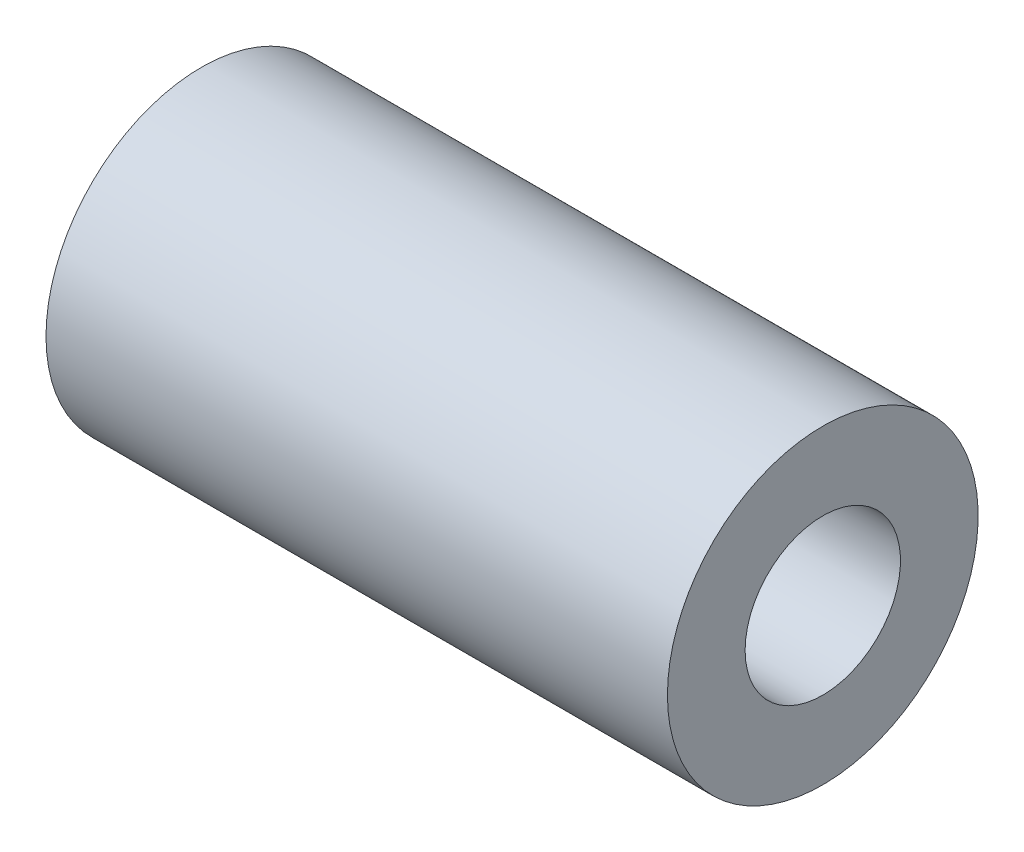
from build123d import *

# Parameters (mm, degrees)
SKETCH1_W         = 10
SKETCH1_H         = 2.5
TROU_TARAUD_M31_D = 2.5


with BuildPart() as part:
    # Sketch1 → Revolve1 (revolve)
    with BuildSketch(Plane.XY):
        with Locations((0, 1.25)):
            Rectangle(SKETCH1_W, SKETCH1_H)
    revolve(axis=Axis((-5, 0, 0), (1, 0, 0)))

    # Trou taraudé M31 (through all)
    with Locations(Plane.ZY.offset(5)):
        with Locations((0, 0)):
            Hole(TROU_TARAUD_M31_D / 2)


solid = part.part
